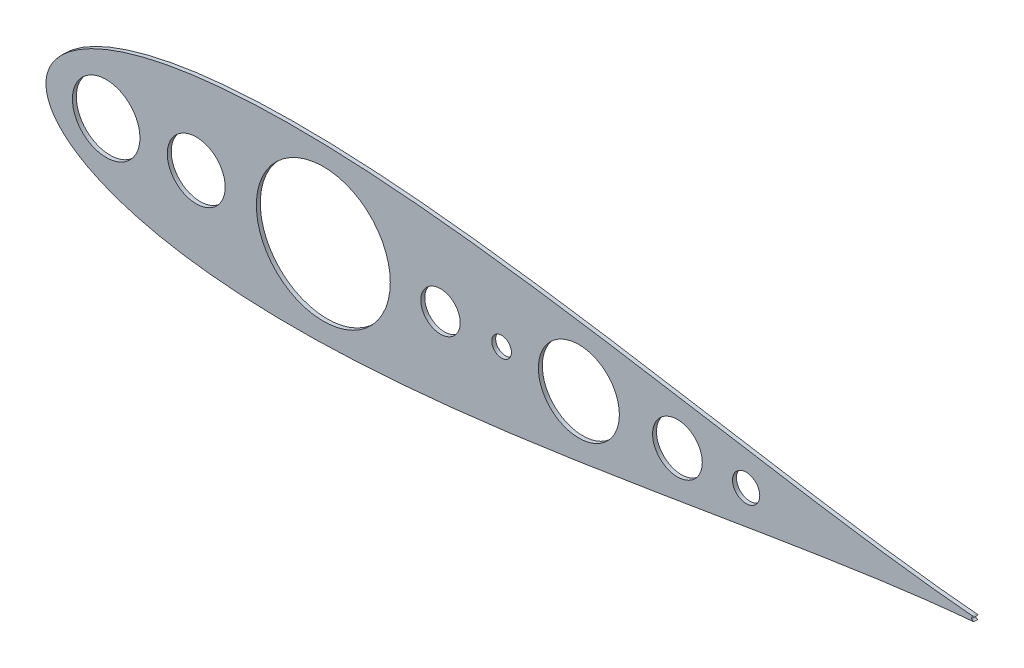
from build123d import *

# Parameters (mm, degrees)
SKETCH2_R           = 18.669
SKETCH2_R_2         = 12.7
SKETCH2_R_3         = 6.35
SKETCH2_R_4         = 16.028770825
SKETCH2_R_5         = 8.77991455
SKETCH2_R_6         = 21.7634135
SKETCH2_R_7         = 26.10316595
SKETCH2_R_8         = 43.16695288
BOSS_EXTRUDE1_DEPTH = 2.54


with BuildPart() as part:
    # Sketch2 → Boss-Extrude1 (new body)
    with BuildSketch(Plane.XY):
        with BuildLine():
            ThreePointArc((890.816164169, 510.477369136), (891.200246589, 510.561868166), (891.54839493, 510.744767386))
            ThreePointArc((891.54839493, 510.744767386), (889.987641801, 511.948825855), (891.54894156, 513.152175424))
            ThreePointArc((891.54894156, 513.152175424), (891.200561464, 513.335347826), (890.816164169, 513.419961885))
            add(Edge.make_bspline(
                [(890.816164169, 513.419961885), (890.334929223, 513.459981199), (886.708241771, 513.765463672), (879.565924572, 514.425614021), (868.964209832, 515.52847142), (857.209813649, 516.881784467), (844.346922273, 518.493665976), (830.435546642, 520.365757129), (815.535846116, 522.493860764), (799.712341782, 524.866984311), (783.032227934, 527.468245813), (765.56538449, 530.274419359), (747.383994901, 533.256521031), (728.562336326, 536.380171049), (709.176538958, 539.605942424), (689.304458457, 542.890066945), (669.025547897, 546.18496062), (648.420790789, 549.440003689), (627.572657185, 552.602222868), (606.565100392, 555.617231647), (585.483547136, 558.429920335), (564.414918298, 560.985438327), (543.447643352, 563.229982453), (522.671673877, 565.111747073), (502.178474967, 566.581679789), (482.06102345, 567.594398694), (462.413787666, 568.109046225), (443.332695328, 568.089939544), (424.915165793, 567.506768629), (407.260111586, 566.336700549), (390.46822582, 564.56276817), (374.642141665, 562.176975248), (359.88739169, 559.178484875), (346.313124377, 555.577330564), (334.03409686, 551.3946178), (323.172804405, 546.667615259), (313.861144192, 541.458918978), (306.23822821, 535.874228771), (300.432417668, 530.09594861), (296.501791132, 524.429595124), (294.309964235, 519.317417687), (293.424863104, 515.216496365), (293.223273347, 511.948665513), (293.424863104, 508.680834661), (294.309964235, 504.579913338), (296.501791132, 499.467735901), (300.432417668, 493.801382415), (306.23822821, 488.023102254), (313.861144192, 482.438412047), (323.172804405, 477.229715766), (334.03409686, 472.502713225), (346.313124377, 468.320000462), (359.88739169, 464.71884615), (374.642141665, 461.720355777), (390.46822582, 459.334562856), (407.260111586, 457.560630476), (424.915165793, 456.390562396), (443.332695328, 455.807391481), (462.413787666, 455.7882848), (482.06102345, 456.302932331), (502.178474967, 457.315651236), (522.671673877, 458.785583952), (543.447643352, 460.667348572), (564.414918298, 462.911892698), (585.483547136, 465.46741069), (606.565100392, 468.280099378), (627.572657185, 471.295108158), (648.420790789, 474.457327336), (669.025547897, 477.712370406), (689.304458457, 481.00726408), (709.176538958, 484.291388601), (728.562336326, 487.517159977), (747.383994901, 490.640809994), (765.56538449, 493.622911666), (783.032227934, 496.429085212), (799.712341782, 499.030346714), (815.535846116, 501.403470261), (830.435546642, 503.531573896), (844.346922273, 505.403665049), (857.209813649, 507.015546558), (868.964209832, 508.368859605), (879.565924572, 509.471717004), (886.708241771, 510.131867354), (890.334929223, 510.437349826), (890.816164169, 510.477369136)],
                knots=[0.020157042, 0.020157042, 0.020157042, 0.020157042, 0.021270888, 0.028552555, 0.036780684, 0.045920102, 0.055931764, 0.066772884, 0.07839713, 0.090754827, 0.103793165, 0.117456432, 0.131686226, 0.146421738, 0.161599998, 0.177156133, 0.193023668, 0.209134786, 0.225420633, 0.241811602, 0.258237647, 0.274628557, 0.290914287, 0.307025229, 0.322892517, 0.338448342, 0.353626207, 0.368361232, 0.382590428, 0.396252961, 0.409290412, 0.42164701, 0.433269881, 0.444109249, 0.45411864, 0.463255055, 0.471479114, 0.478755289, 0.485052318, 0.490344026, 0.494609833, 0.497833231, 0.5, 0.502166769, 0.505390167, 0.509655974, 0.514947682, 0.521244711, 0.528520886, 0.536744945, 0.54588136, 0.555890751, 0.566730119, 0.57835299, 0.590709588, 0.603747039, 0.617409572, 0.631638768, 0.646373793, 0.661551658, 0.677107483, 0.692974771, 0.709085713, 0.725371443, 0.741762353, 0.758188398, 0.774579367, 0.790865214, 0.806976332, 0.822843867, 0.838400002, 0.853578262, 0.868313774, 0.882543568, 0.896206835, 0.909245173, 0.92160287, 0.933227116, 0.944068236, 0.954079898, 0.963219316, 0.971447445, 0.978729112, 0.979842958, 0.979842958, 0.979842958, 0.979842958], degree=3))
        make_face()
        with Locations((390.131274336, 511.948665509)):
            Circle(SKETCH2_R, mode=Mode.SUBTRACT)
        with Locations((547.611274336, 511.948665509)):
            Circle(SKETCH2_R_2, mode=Mode.SUBTRACT)
        with Locations((586.981274336, 511.948665509)):
            Circle(SKETCH2_R_3, mode=Mode.SUBTRACT)
        with Locations((700.323442246, 511.948665509)):
            Circle(SKETCH2_R_4, mode=Mode.SUBTRACT)
        with Locations((744.61753791, 511.948665509)):
            Circle(SKETCH2_R_5, mode=Mode.SUBTRACT)
        with Locations((332.073077219, 511.901802055)):
            Circle(SKETCH2_R_6, mode=Mode.SUBTRACT)
        with Locations((636.787882815, 511.948665509)):
            Circle(SKETCH2_R_7, mode=Mode.SUBTRACT)
        with Locations((472.050636064, 511.901802055)):
            Circle(SKETCH2_R_8, mode=Mode.SUBTRACT)
    extrude(amount=BOSS_EXTRUDE1_DEPTH)


solid = part.part
